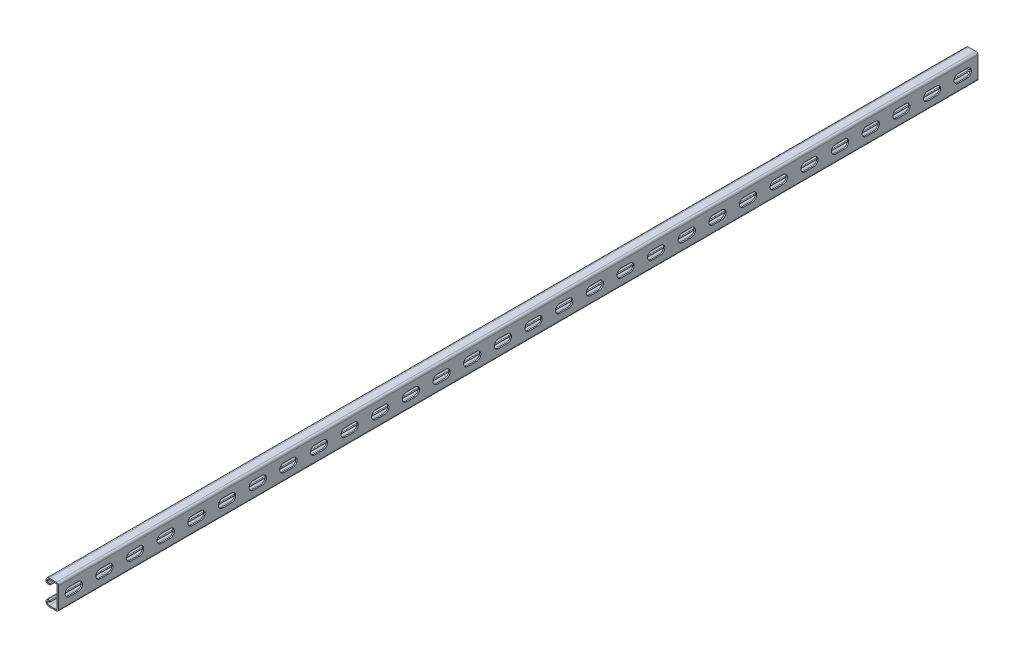
from build123d import *

# Parameters (mm, degrees)
BOSS_EXTRUDE1_DEPTH = 1524
CUT_EXTRUDE1_DEPTH  = 2.032
LPATTERN1_COUNT     = 30
LPATTERN1_PITCH     = 50.8


with BuildPart() as part:
    # Sketch1 → Boss-Extrude1 (new body)
    with BuildSketch(Plane.XY):
        with BuildLine():
            Line((-15.58925, 20.6375), (-3.46075, 20.6375))
            ThreePointArc((-3.46075, 20.6375), (-1.013630207, 19.623869793), (0, 17.17675))
            Line((0, 17.17675), (0, -17.17675))
            ThreePointArc((0, -17.17675), (-1.013630207, -19.623869793), (-3.46075, -20.6375))
            Line((-3.46075, -20.6375), (-15.58925, -20.6375))
            ThreePointArc((-15.58925, -20.6375), (-19.158901808, -19.158901808), (-20.6375, -15.58925))
            Line((-20.6375, -15.58925), (-20.6375, -14.57325))
            ThreePointArc((-20.6375, -14.57325), (-19.623869793, -12.126130207), (-17.17675, -11.1125))
            Line((-17.17675, -11.1125), (-14.5161, -11.1125))
            ThreePointArc((-14.5161, -11.1125), (-13.5001, -12.1285), (-14.5161, -13.1445))
            Line((-14.5161, -13.1445), (-17.17675, -13.1445))
            ThreePointArc((-17.17675, -13.1445), (-18.187028814, -13.562971186), (-18.6055, -14.57325))
            Line((-18.6055, -14.57325), (-18.6055, -15.58925))
            ThreePointArc((-18.6055, -15.58925), (-17.722060829, -17.722060829), (-15.58925, -18.6055))
            Line((-15.58925, -18.6055), (-3.46075, -18.6055))
            ThreePointArc((-3.46075, -18.6055), (-2.450471186, -18.187028814), (-2.032, -17.17675))
            Line((-2.032, -17.17675), (-2.032, 17.17675))
            ThreePointArc((-2.032, 17.17675), (-2.450471186, 18.187028814), (-3.46075, 18.6055))
            Line((-3.46075, 18.6055), (-15.58925, 18.6055))
            ThreePointArc((-15.58925, 18.6055), (-17.722060829, 17.722060829), (-18.6055, 15.58925))
            Line((-18.6055, 15.58925), (-18.6055, 14.57325))
            ThreePointArc((-18.6055, 14.57325), (-18.187028814, 13.562971186), (-17.17675, 13.1445))
            Line((-17.17675, 13.1445), (-14.5161, 13.1445))
            ThreePointArc((-14.5161, 13.1445), (-13.5001, 12.1285), (-14.5161, 11.1125))
            Line((-14.5161, 11.1125), (-17.17675, 11.1125))
            ThreePointArc((-17.17675, 11.1125), (-19.623869793, 12.126130207), (-20.6375, 14.57325))
            Line((-20.6375, 14.57325), (-20.6375, 15.58925))
            ThreePointArc((-20.6375, 15.58925), (-19.158901808, 19.158901808), (-15.58925, 20.6375))
        make_face()
    extrude(amount=-BOSS_EXTRUDE1_DEPTH)

    # Sketch2 → Cut-Extrude1 (cut)
    with BuildSketch(Plane(origin=(0, 0, 0), x_dir=(0, 0, -1), z_dir=(1, 0, 0))):
        with BuildLine():
            Line((18.25625, 7.14375), (32.54375, 7.14375))
            ThreePointArc((32.54375, 7.14375), (39.6875, 0), (32.54375, -7.14375))
            Line((32.54375, -7.14375), (18.25625, -7.14375))
            ThreePointArc((18.25625, -7.14375), (11.1125, 0), (18.25625, 7.14375))
        make_face()
    cut_extrude1 = extrude(amount=-CUT_EXTRUDE1_DEPTH, mode=Mode.SUBTRACT)

    # LPattern1: Cut-Extrude1 ×30
    with Locations(*[(0, 0, -i * LPATTERN1_PITCH) for i in range(1, LPATTERN1_COUNT)]):
        add(cut_extrude1, mode=Mode.SUBTRACT)


solid = part.part
